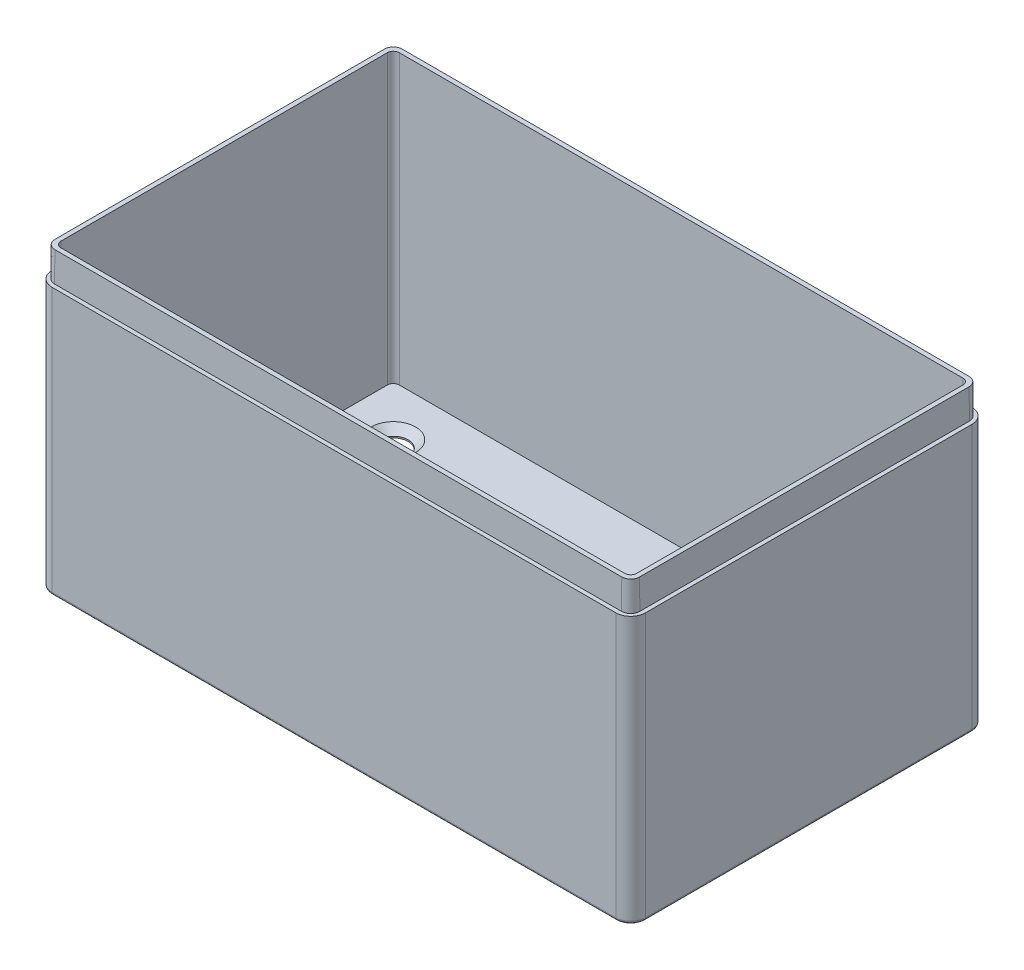
from build123d import *

# Parameters (mm, degrees)
BOSS_EXTRUDE1_DEPTH = 50
SHELL1_T            = -1.5
SKETCH2_R           = 2.5
CUT_EXTRUDE1_DEPTH  = 50
SKETCH3_OUTSIDE_W   = 127.464
SKETCH3_OUTSIDE_H   = 87.464
CUT_EXTRUDE2_DEPTH  = 5
CUT_EXTRUDE2_TAPER  = 0.5
FILLET1_R           = 0.5
CHAMFER1_SIZE       = 1.25


with BuildPart() as part:
    # Sketch1 → Boss-Extrude1 (new body)
    with BuildSketch(Plane(origin=(0, 0, 0), x_dir=(1, 0, 0), z_dir=(0, 1, 0))):
        with BuildLine():
            Line((-47.5, -30), (47.5, -30))
            ThreePointArc((47.5, -30), (49.267766953, -29.267766953), (50, -27.5))
            Line((50, -27.5), (50, 27.5))
            ThreePointArc((50, 27.5), (49.267766953, 29.267766953), (47.5, 30))
            Line((47.5, 30), (-47.5, 30))
            ThreePointArc((-47.5, 30), (-49.267766953, 29.267766953), (-50, 27.5))
            Line((-50, 27.5), (-50, -27.5))
            ThreePointArc((-50, -27.5), (-49.267766953, -29.267766953), (-47.5, -30))
        make_face()
    extrude(amount=BOSS_EXTRUDE1_DEPTH)

    # Shell1
    shell1_openings = [part.faces().sort_by_distance(p)[0] for p in [
        (0, 50, 0),
    ]]
    offset(amount=SHELL1_T, openings=shell1_openings, kind=Kind.INTERSECTION)

    # Sketch2 → Cut-Extrude1 (cut)
    with BuildSketch(Plane(origin=(0, 1.5, 0), x_dir=(1, 0, 0), z_dir=(0, 1, 0))):
        with Locations((-40, 20)):
            Circle(SKETCH2_R)
        with Locations((40, 20)):
            Circle(SKETCH2_R)
        with Locations((40, -20)):
            Circle(SKETCH2_R)
        with Locations((-40, -20)):
            Circle(SKETCH2_R)
    extrude(amount=-CUT_EXTRUDE1_DEPTH, mode=Mode.SUBTRACT)

    # Sketch3 outside → Cut-Extrude2 (cut)
    with BuildSketch(Plane(origin=(0, 50, 0), x_dir=(1, 0, 0), z_dir=(0, 1, 0))):
        Rectangle(SKETCH3_OUTSIDE_W, SKETCH3_OUTSIDE_H)
        with BuildLine():
            Line((-47.767766953, -29.267766953), (47.767766953, -29.267766953))
            ThreePointArc((47.767766953, -29.267766953), (48.828427125, -28.828427125), (49.267766953, -27.767766953))
            Line((49.267766953, -27.767766953), (49.267766953, 27.767766953))
            ThreePointArc((49.267766953, 27.767766953), (48.828427125, 28.828427125), (47.767766953, 29.267766953))
            Line((47.767766953, 29.267766953), (-47.767766953, 29.267766953))
            ThreePointArc((-47.767766953, 29.267766953), (-48.828427125, 28.828427125), (-49.267766953, 27.767766953))
            Line((-49.267766953, 27.767766953), (-49.267766953, -27.767766953))
            ThreePointArc((-49.267766953, -27.767766953), (-48.828427125, -28.828427125), (-47.767766953, -29.267766953))
        make_face(mode=Mode.SUBTRACT)
    extrude(amount=-CUT_EXTRUDE2_DEPTH, taper=CUT_EXTRUDE2_TAPER, mode=Mode.SUBTRACT)

    # Fillet1
    fillet1_edges = [part.edges().sort_by_distance(p)[0] for p in [
        (-50, 0, 0),
        (-49.267766953, 0, -29.267766953),
        (0, 0, -30),
        (49.267766953, 0, -29.267766953),
        (50, 0, 0),
        (49.267766953, 0, 29.267766953),
        (0, 0, 30),
        (-49.267766953, 0, 29.267766953),
    ]]
    fillet(fillet1_edges, radius=FILLET1_R)

    # Chamfer1
    chamfer1_edges = [part.edges().sort_by_distance(p)[0] for p in [
        (-42.5, 1.5, -20),
        (37.5, 1.5, -20),
        (37.5, 1.5, 20),
        (-42.5, 1.5, 20),
    ]]
    chamfer(chamfer1_edges, length=CHAMFER1_SIZE)


solid = part.part
